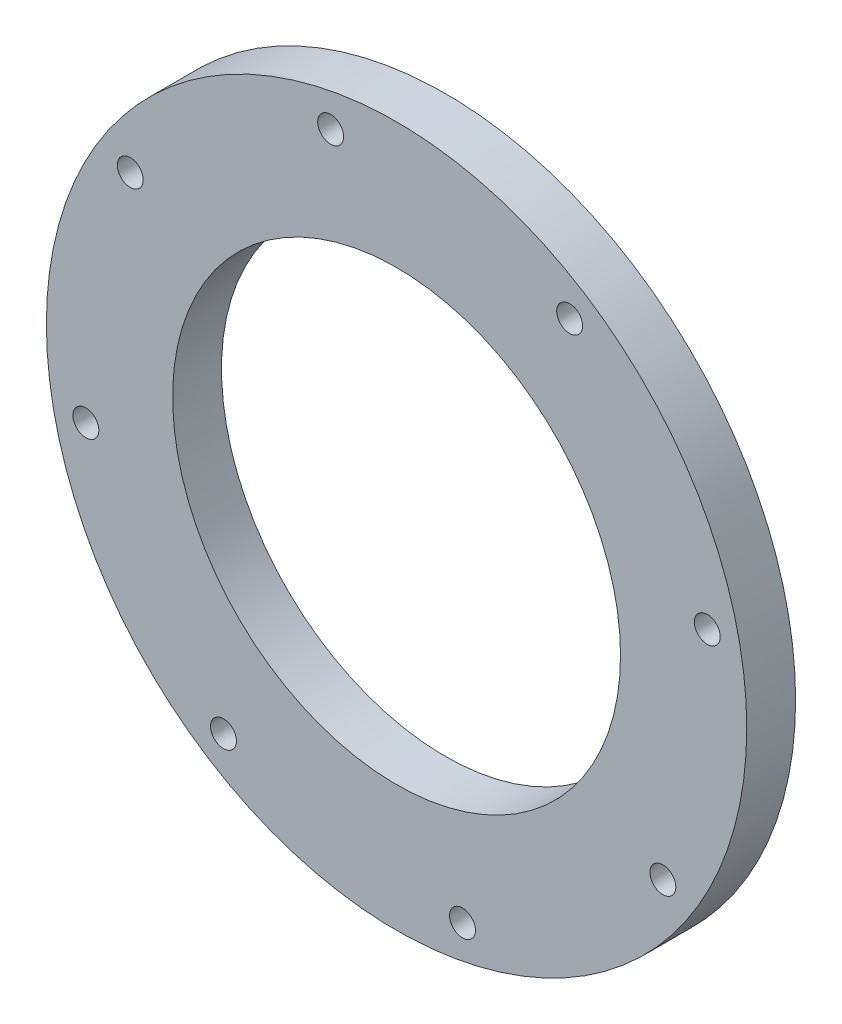
from build123d import *

# Parameters (mm, degrees)
SKETCH1_R           = 54.61
SKETCH1_R_2         = 34.925
BOSS_EXTRUDE1_DEPTH = 7.62
SKETCH3_R           = 2.0193
CUT_EXTRUDE1_DEPTH  = 8.62


with BuildPart() as part:
    # Sketch1 → Boss-Extrude1 (new body)
    with BuildSketch(Plane.XY):
        Circle(SKETCH1_R)
        Circle(SKETCH1_R_2, mode=Mode.SUBTRACT)
    extrude(amount=BOSS_EXTRUDE1_DEPTH)

    # Sketch3 → Cut-Extrude1 (cut, through all)
    with BuildSketch(Plane(origin=(0, 0, 0), x_dir=(-1, 0, 0), z_dir=(0, 0, -1))):
        with Locations((41.529703671, 26.990824607)):
            Circle(SKETCH3_R)
        with Locations((10.280539977, 48.451330196)):
            Circle(SKETCH3_R)
        with Locations((-26.990824607, 41.529703671)):
            Circle(SKETCH3_R)
        with Locations((-48.451330196, 10.280539977)):
            Circle(SKETCH3_R)
        with Locations((-41.529703671, -26.990824607)):
            Circle(SKETCH3_R)
        with Locations((-10.280539977, -48.451330196)):
            Circle(SKETCH3_R)
        with Locations((26.990824607, -41.529703671)):
            Circle(SKETCH3_R)
        with Locations((48.451330196, -10.280539977)):
            Circle(SKETCH3_R)
    extrude(amount=-CUT_EXTRUDE1_DEPTH, mode=Mode.SUBTRACT)


solid = part.part
